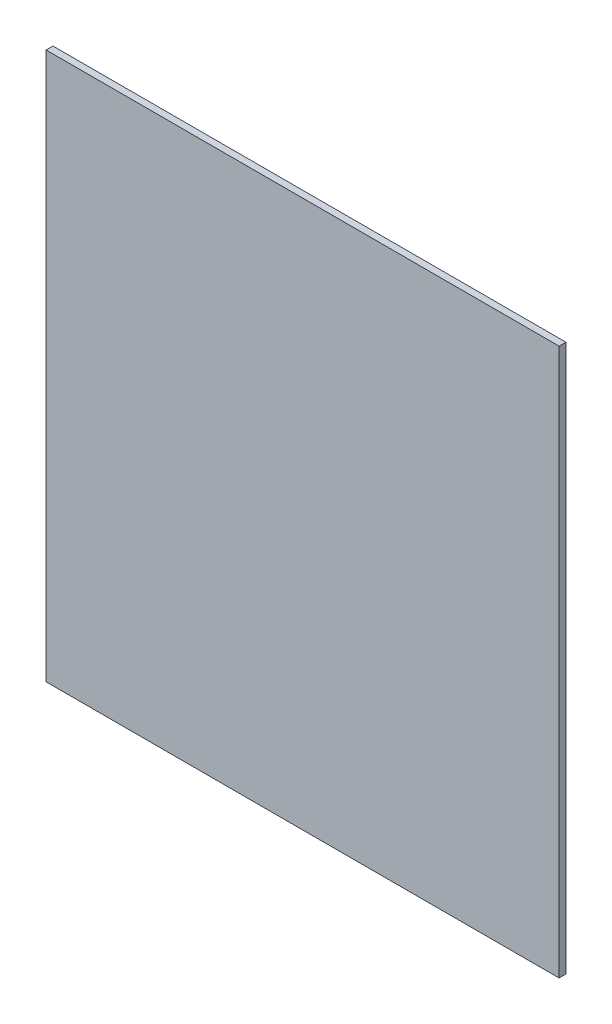
from build123d import *

# Parameters (mm, degrees)
SKETCH1_W        = 150
SKETCH1_H        = 160
SIDE_DOORS_DEPTH = 2


with BuildPart() as part:
    # Sketch1 → Side_doors (new body)
    with BuildSketch(Plane.XY):
        with Locations((88, 152.1)):
            Rectangle(SKETCH1_W, SKETCH1_H)
    extrude(amount=-SIDE_DOORS_DEPTH)


solid = part.part
